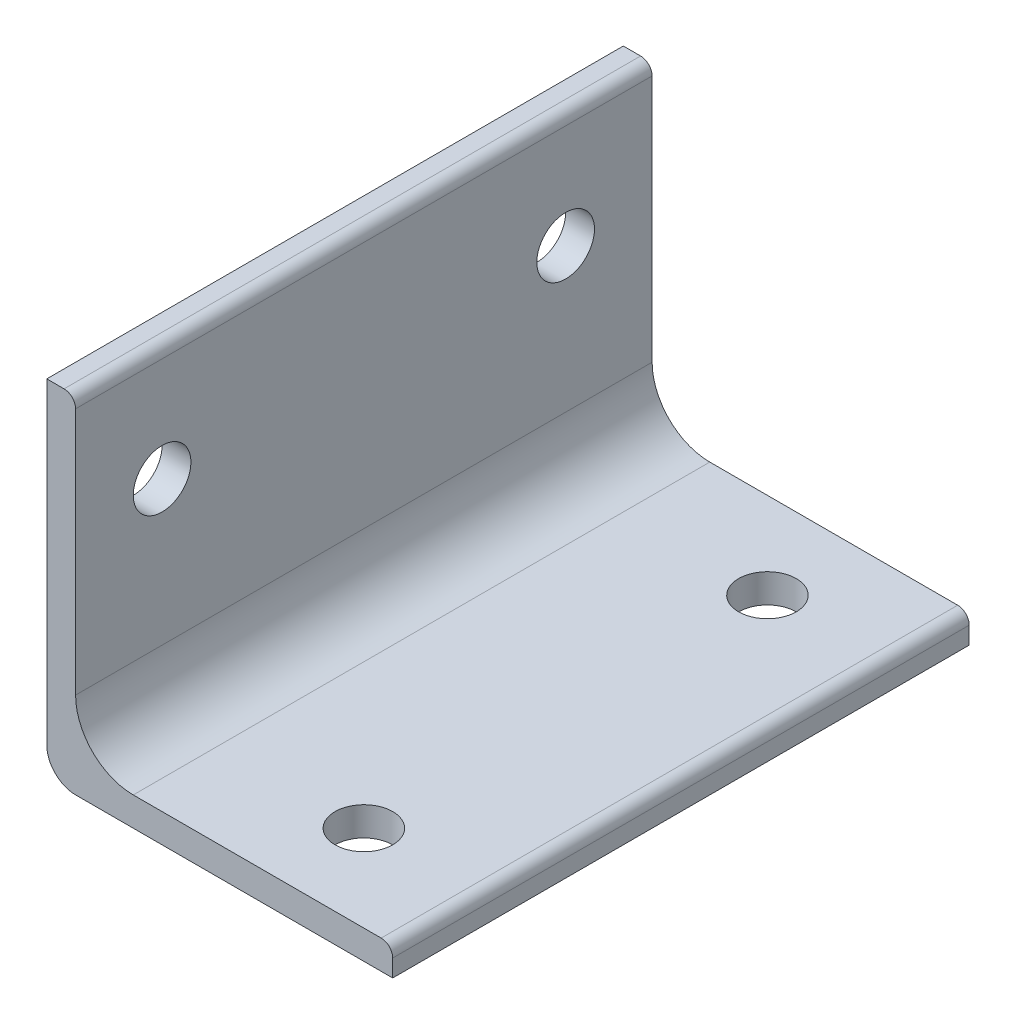
from build123d import *

# Parameters (mm, degrees)
BOSS_EXTRUDE1_DEPTH                   = 63.5
F_1_4_0_25_DIAMETER_HOLE1_D           = 6.35
F_1_4_0_25_DIAMETER_HOLE1_ON_FACE_2_D = 6.35


with BuildPart() as part:
    # Sketch3 → Boss-Extrude1 (new body)
    with BuildSketch(Plane.XY):
        with BuildLine():
            Line((0, 6.35), (0, 33.655))
            ThreePointArc((0, 33.655), (-0.371974388, 34.553025612), (-1.27, 34.925))
            Line((-1.27, 34.925), (-3.175, 34.925))
            Line((-3.175, 34.925), (-3.175, 0))
            ThreePointArc((-3.175, 0), (-2.24506403, -2.24506403), (0, -3.175))
            Line((0, -3.175), (34.925, -3.175))
            Line((34.925, -3.175), (34.925, -1.27))
            ThreePointArc((34.925, -1.27), (34.553025612, -0.371974388), (33.655, 0))
            Line((33.655, 0), (6.35, 0))
            ThreePointArc((6.35, 0), (1.859871939, 1.859871939), (0, 6.35))
        make_face()
    extrude(amount=BOSS_EXTRUDE1_DEPTH)

    # 1/4 (0.25) Diameter Hole1 (through all)
    with Locations(Plane(origin=(22.225, 0, 53.975), x_dir=(1, 0, 0), z_dir=(0, 1, 0))):
        with Locations((0, 0), (0, 44.45)):
            Hole(F_1_4_0_25_DIAMETER_HOLE1_D / 2)

    # 1/4 (0.25) Diameter Hole1 on face 2 (through all)
    with Locations(Plane(origin=(0, 22.225, 9.525), x_dir=(0, 0, 1), z_dir=(1, 0, 0))):
        with Locations((0, 0), (44.45, 0)):
            Hole(F_1_4_0_25_DIAMETER_HOLE1_ON_FACE_2_D / 2)


solid = part.part
